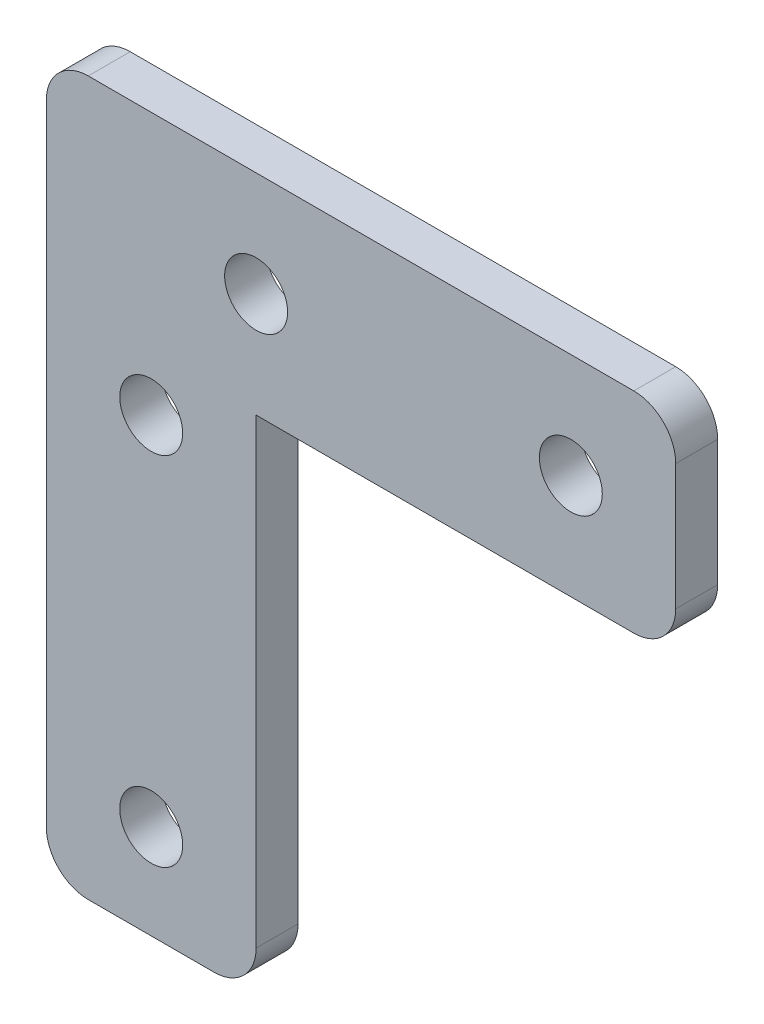
from build123d import *

# Parameters (mm, degrees)
SKETCH1_R           = 1.5
BOSS_EXTRUDE1_DEPTH = 2
FILLET1_R           = 2


with BuildPart() as part:
    # Sketch1 → Boss-Extrude1 (new body)
    with BuildSketch(Plane.XY):
        Polygon((-5, 12), (-5, -12), (5, -12), (5, 12), (25, 12), (25, 22), (-5, 22), align=None)
        with Locations((0, 9.5)):
            Circle(SKETCH1_R, mode=Mode.SUBTRACT)
        with Locations((0, -7.5)):
            Circle(SKETCH1_R, mode=Mode.SUBTRACT)
        with Locations((5, 17)):
            Circle(SKETCH1_R, mode=Mode.SUBTRACT)
        with Locations((20, 17)):
            Circle(SKETCH1_R, mode=Mode.SUBTRACT)
    extrude(amount=BOSS_EXTRUDE1_DEPTH)

    # Fillet1
    fillet1_edges = [part.edges().sort_by_distance(p)[0] for p in [
        (5, -12, 1),
        (-5, -12, 1),
        (-5, 22, 1),
        (25, 22, 1),
        (25, 12, 1),
    ]]
    fillet(fillet1_edges, radius=FILLET1_R)


solid = part.part
